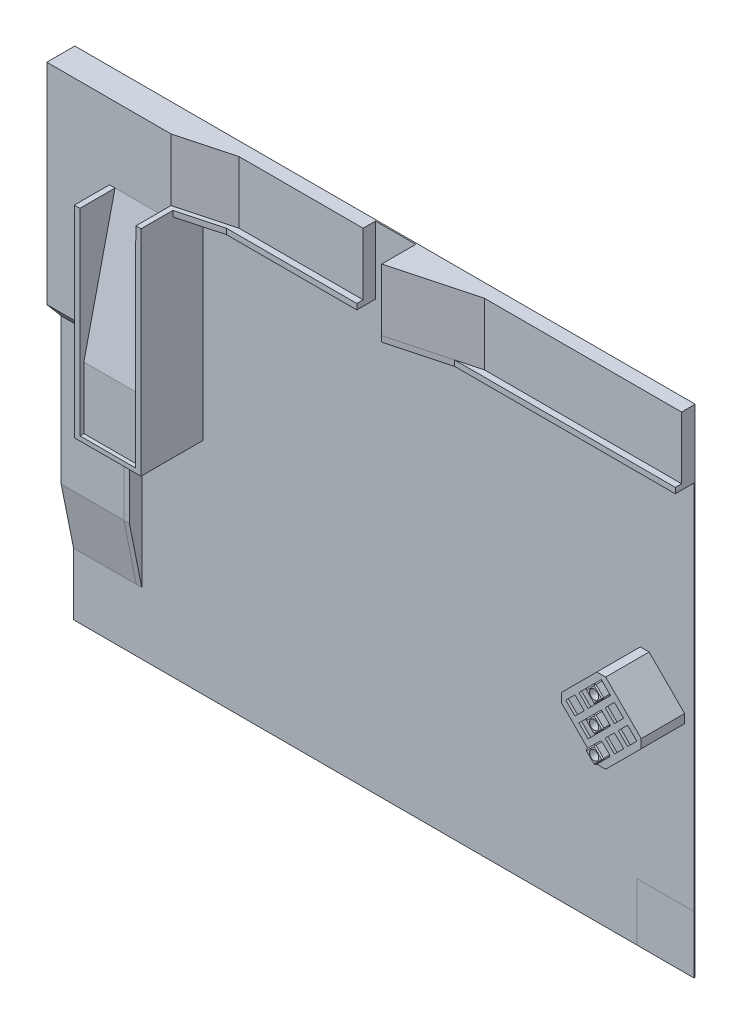
from build123d import *

# Parameters (mm, degrees)
SKETCH_1_W                  = 10000
SKETCH_1_H                  = 8000
EXTRUDE_1_DEPTH             = 20
SKETCH_2_W                  = 4483
SKETCH_2_H                  = 1000
EXTRUDE_2_DEPTH             = 200
EXTRUDE_3_DEPTH             = 1000
SKETCH_5_W                  = 2867
SKETCH_5_H                  = 1000
EXTRUDE_4_DEPTH             = 200
EXTRUDE_5_DEPTH             = 1000
SKETCH_7_W                  = 2000
SKETCH_7_H                  = 3383
EXTRUDE_6_DEPTH             = 431.88915
EXTRUDE_7_DEPTH             = 2000
SKETCH_10_W                 = 1100
SKETCH_10_H                 = 934.292466456
CUT_EXTRUDE_1_DEPTH         = 2176.14786
EXTRUDE_START               = -4e-06
SKETCH_11_W                 = 1100
SKETCH_11_H                 = 431.889147349
EXTRUDE_8_DEPTH             = 2176.14786
SKETCH_12_W                 = 900
SKETCH_12_H                 = 1000
EXTRUDE_9_DEPTH             = 934.292466
EXTRUDE_10_DEPTH            = 1100
SKETCH_16_W                 = 1100
SKETCH_16_H                 = 200
EXTRUDE_11_DEPTH            = 2622
EXTRUDE_12_DEPTH            = 1100
EXTRUDE_13_DEPTH            = 1018
SKETCH_22_W                 = 82.675943171
SKETCH_22_H                 = 996.089113944
EXTRUDE_14_DEPTH            = 206.852144
SKETCH_23_W                 = 1000
SKETCH_23_H                 = 90
EXTRUDE_15_DEPTH            = 2782.251832
CUT_EXTRUDE_2_DEPTH         = 308
SKETCH_25_W                 = 296.558009181
SKETCH_25_H                 = 236.726130136
CUT_EXTRUDE_3_DEPTH         = 3067
EXTRUDE_START_2             = -4483
SKETCH_26_W                 = 299.612595247
SKETCH_26_H                 = 90
EXTRUDE_16_DEPTH            = 4483
EXTRUDE_17_DEPTH            = 90
EXTRUDE_18_DEPTH            = 700
CHAMFER_1_SIZE              = 100
CUT_EXTRUDE_5_DEPTH         = 42
PATTERN_LINEAR_2_COUNT      = 3
PATTERN_LINEAR_2_PITCH      = 300
PATTERN_LINEAR_2_COUNT_DIR2 = 3
PATTERN_LINEAR_2_PITCH_DIR2 = 300
EXTRUDE_19_DEPTH            = 158
CHAMFER_4_SIZE              = 18
CHAMFER_5_SIZE              = 18
EXTRUDE_20_DEPTH            = 116
CHAMFER_6_SIZE              = 18
CHAMFER_7_SIZE              = 18
EXTRUDE_21_DEPTH            = 116
CHAMFER_8_SIZE              = 18
SKETCH_41_R                 = 75
CUT_EXTRUDE_6_DEPTH         = 164
SKETCH_42_R                 = 75
CUT_EXTRUDE_7_DEPTH         = 164
SKETCH_43_R                 = 75
CUT_EXTRUDE_8_DEPTH         = 164


with BuildPart() as part:
    # 草图1 → 凸台-拉伸1 (new body)
    with BuildSketch(Plane.XY):
        with Locations((5000, 4000)):
            Rectangle(SKETCH_1_W, SKETCH_1_H)
    extrude(amount=EXTRUDE_1_DEPTH)

    # 草图2 → 凸台-拉伸2 (add)
    with BuildSketch(Plane.XY.offset(20)):
        with Locations((7758.5, 7500)):
            Rectangle(SKETCH_2_W, SKETCH_2_H)
    extrude(amount=EXTRUDE_2_DEPTH)

    # 草图3 → 凸台-拉伸3 (add)
    with BuildSketch(Plane(origin=(0, 8000, 0), x_dir=(1, 0, 0), z_dir=(0, 1, 0))):
        Polygon((5517, -220), (5517, -570), (6823, -220), align=None)
    extrude(amount=-EXTRUDE_3_DEPTH)

    # 草图5 → 凸台-拉伸4 (add)
    with BuildSketch(Plane.XY.offset(20)):
        with Locations((3433.5, 7500)):
            Rectangle(SKETCH_5_W, SKETCH_5_H)
    extrude(amount=EXTRUDE_4_DEPTH)

    # 草图6 → 凸台-拉伸5 (add)
    with BuildSketch(Plane(origin=(0, 8000, 0), x_dir=(1, 0, 0), z_dir=(0, 1, 0))):
        Polygon((2000, -220), (2865.42207963, -220), (2000, -451.889147349), align=None)
    extrude(amount=-EXTRUDE_5_DEPTH)

    # 草图7 → 凸台-拉伸6 (add)
    with BuildSketch(Plane.XY.offset(20)):
        with Locations((1000, 6308.5)):
            Rectangle(SKETCH_7_W, SKETCH_7_H)
    extrude(amount=EXTRUDE_6_DEPTH)

    # 草图9 → 凸台-拉伸7 (add)
    with BuildSketch(Plane(origin=(2000, 0, 0), x_dir=(0, 0, -1), z_dir=(1, 0, 0))):
        Polygon((-451.889147349, 4617), (-451.889147349, 6793.147855873), (-954.292466456, 4617), align=None)
    extrude(amount=-EXTRUDE_7_DEPTH)

    # 草图10 → 切除-拉伸1 (cut)
    with BuildSketch(Plane.XZ.offset(-4617)):
        with Locations((550, 487.146233228)):
            Rectangle(SKETCH_10_W, SKETCH_10_H)
    extrude(amount=-CUT_EXTRUDE_1_DEPTH, mode=Mode.SUBTRACT)

    # 草图11 → 凸台-拉伸8 (add)
    with BuildSketch(Plane.XZ.offset(-6793.147855873).offset(EXTRUDE_START)):
        with Locations((550, 235.944573675)):
            Rectangle(SKETCH_11_W, SKETCH_11_H)
    extrude(amount=EXTRUDE_8_DEPTH)

    # 草图12 → 凸台-拉伸9 (add)
    with BuildSketch(Plane.XY.offset(20)):
        with Locations((1550, 4117)):
            Rectangle(SKETCH_12_W, SKETCH_12_H)
    extrude(amount=EXTRUDE_9_DEPTH)

    # 草图14 → 凸台-拉伸10 (add)
    with BuildSketch(Plane.ZY.offset(-1100)):
        Polygon((220, 4342), (220, 4617), (451.889147349, 4617), align=None)
    extrude(amount=EXTRUDE_10_DEPTH)

    # 草图16 → 凸台-拉伸11 (add)
    with BuildSketch(Plane.XZ.offset(-4617)):
        with Locations((550, 120)):
            Rectangle(SKETCH_16_W, SKETCH_16_H)
    extrude(amount=EXTRUDE_11_DEPTH)

    # 草图17 → 凸台-拉伸12 (add)
    with BuildSketch(Plane.ZY):
        Polygon((20, 1995), (20, 1000), (220, 1995), align=None)
    extrude(amount=-EXTRUDE_12_DEPTH)

    # 草图18 → 凸台-拉伸13 (add)
    with BuildSketch(Plane.XY):
        Polygon((1100, 6793.147855873), (1010, 6793.147855873), (1010, 3545.906358022), (2084.748167595, 3545.906358022), (2084.748167595, 6793.147855873), (2000, 6793.147855873), (2000, 3617), (1100, 3617), align=None)
    extrude(amount=EXTRUDE_13_DEPTH)

    # 草图22 → 凸台-拉伸14 (add)
    with BuildSketch(Plane(origin=(0, 6793.147855873, 0), x_dir=(1, 0, 0), z_dir=(0, 1, 0))):
        with Locations((2043.41019601, -519.955443028)):
            Rectangle(SKETCH_22_W, SKETCH_22_H)
    extrude(amount=EXTRUDE_14_DEPTH)

    # 草图23 → 凸台-拉伸15 (add)
    with BuildSketch(Plane(origin=(2084.748167595, 0, 0), x_dir=(0, 0, -1), z_dir=(1, 0, 0))):
        with Locations((-521.910886056, 6955)):
            Rectangle(SKETCH_23_W, SKETCH_23_H)
    extrude(amount=EXTRUDE_15_DEPTH)

    # 草图24 → 切除-拉伸2 (cut)
    with BuildSketch(Plane(origin=(0, 7000, 0), x_dir=(1, 0, 0), z_dir=(0, 1, 0))):
        Polygon((2084.748167595, -1018), (2084.748167595, -504.330547982), (2764.317775175, -321.523481303), (4867, -321.523481303), (4867, -1021.910886056), align=None)
    extrude(amount=-CUT_EXTRUDE_2_DEPTH, mode=Mode.SUBTRACT)


with BuildPart() as cut_extrude_2_piece_1:
    # of the separate pieces the step leaves, piece 1, a body of its own (cut_extrude_2_pieces)
    add(part.part.solids().sort_by_distance((0, 0, 0))[0])

    # 草图26 → 凸台-拉伸16 (add)
    with BuildSketch(Plane(origin=(10000, 0, 0), x_dir=(0, 0, -1), z_dir=(1, 0, 0)).offset(EXTRUDE_START_2)):
        with Locations((-171.71718368, 6955)):
            Rectangle(SKETCH_26_W, SKETCH_26_H)
    extrude(amount=EXTRUDE_16_DEPTH)

    # 草图27 → 凸台-拉伸17 (add)
    with BuildSketch(Plane.XZ.offset(-7000)):
        Polygon((5517, 570), (5517, 321.523481303), (6444.172381196, 321.523481303), align=None)
    extrude(amount=EXTRUDE_17_DEPTH)

    # 草图32 → 凸台-拉伸18 (add)
    with BuildSketch(Plane.XY.offset(20)):
        Polygon((9920.278281584, 3545.906358022), (9206.100432586, 4260.084207021), (8491.922583587, 3545.906358022), (9206.100432586, 2831.728509024), align=None)
    extrude(amount=EXTRUDE_18_DEPTH)

    # 倒角1
    chamfer_1_edges = [cut_extrude_2_piece_1.edges().sort_by_distance(p)[0] for p in [
        (9206.100432586, 2831.728509024, 370),
        (9920.278281584, 3545.906358022, 370),
        (9206.100432586, 4260.084207021, 370),
        (8491.922583587, 3545.906358022, 370),
    ]]
    chamfer(chamfer_1_edges, length=CHAMFER_1_SIZE)

    # 草图35 → 切除-拉伸5 (cut)
    with BuildSketch(Plane.XY.offset(720)):
        Polygon((8633.343939825, 3545.906358022), (8781.836363874, 3694.398782071), (8930.328787923, 3545.906358022), (8781.836363874, 3397.413933973), align=None)
    cut_extrude_5 = extrude(amount=-CUT_EXTRUDE_5_DEPTH, mode=Mode.SUBTRACT)

    # 阵列(线性)2: Cut-Extrude 5 3 × 3
    with Locations(*[Vector(0.7071067811865527, -0.7071067811865424, 0) * (i * PATTERN_LINEAR_2_PITCH) + Vector(0.7071067811865408, 0.7071067811865542, 0) * (j * PATTERN_LINEAR_2_PITCH_DIR2) for i in range(PATTERN_LINEAR_2_COUNT) for j in range(PATTERN_LINEAR_2_COUNT_DIR2) if (i, j) != (0, 0)]):
        add(cut_extrude_5, mode=Mode.SUBTRACT)

    # 草图36 → 凸台-拉伸19 (add)
    with BuildSketch(Plane.XY.offset(678)):
        Polygon((9057.608008537, 3121.64228931), (9206.100432586, 3270.134713359), (9354.592856635, 3121.64228931), (9206.100432586, 2973.149865261), align=None)
    extrude(amount=EXTRUDE_19_DEPTH)

    # 倒角4
    chamfer_4_edges = [cut_extrude_2_piece_1.edges().sort_by_distance(p)[0] for p in [
        (9131.854220561, 3047.396077286, 836),
        (9280.34664461, 3047.396077286, 836),
        (9280.34664461, 3195.888501335, 836),
        (9131.854220561, 3195.888501335, 836),
    ]]
    chamfer(chamfer_4_edges, length=CHAMFER_4_SIZE)

    # 倒角5
    chamfer_5_edges = [cut_extrude_2_piece_1.edges().sort_by_distance(p)[0] for p in [
        (9057.608008537, 3121.64228931, 769),
        (9206.100432586, 3270.134713359, 769),
        (9354.592856635, 3121.64228931, 769),
        (9206.100432586, 2973.149865261, 769),
    ]]
    chamfer(chamfer_5_edges, length=CHAMFER_5_SIZE)


with BuildPart() as cut_extrude_2_piece_2:
    # of the separate pieces the step leaves, piece 2, a body of its own (cut_extrude_2_pieces)
    add(part.part.solids().sort_by_distance((2084.748167595, 6910, 1021.910886056))[0])

    # 草图25 → 切除-拉伸3 (cut)
    with BuildSketch(Plane(origin=(2084.748167595, 0, 0), x_dir=(0, 0, -1), z_dir=(1, 0, 0))):
        with Locations((-1038.303536701, 6926.915216344)):
            Rectangle(SKETCH_25_W, SKETCH_25_H)
    extrude(amount=CUT_EXTRUDE_3_DEPTH, mode=Mode.SUBTRACT)


with BuildPart() as body_2:
    # 草图37 → 凸台-拉伸20 (new body)
    with BuildSketch(Plane.XY.offset(720)):
        Polygon((9057.608008537, 3545.906358022), (9206.100432586, 3397.413933973), (9354.592856635, 3545.906358022), (9206.100432586, 3694.398782071), align=None)
    extrude(amount=EXTRUDE_20_DEPTH)

    # 倒角6
    chamfer_6_edges = [body_2.edges().sort_by_distance(p)[0] for p in [
        (9280.34664461, 3471.660145998, 836),
        (9280.34664461, 3620.152570047, 836),
        (9131.854220561, 3620.152570047, 836),
        (9131.854220561, 3471.660145998, 836),
    ]]
    chamfer(chamfer_6_edges, length=CHAMFER_6_SIZE)

    # 倒角7
    chamfer_7_edges = [body_2.edges().sort_by_distance(p)[0] for p in [
        (9206.100432586, 3694.398782071, 769),
        (9354.592856635, 3545.906358022, 769),
        (9057.608008537, 3545.906358022, 769),
        (9206.100432586, 3397.413933973, 769),
    ]]
    chamfer(chamfer_7_edges, length=CHAMFER_7_SIZE)


with BuildPart() as body_3:
    # 草图38 → 凸台-拉伸21 (new body)
    with BuildSketch(Plane.XY.offset(720)):
        Polygon((9057.608008537, 3970.170426734), (9206.100432586, 4118.662850783), (9354.592856635, 3970.170426734), (9206.100432586, 3821.678002685), align=None)
    extrude(amount=EXTRUDE_21_DEPTH)

    # 倒角8
    chamfer_8_edges = [body_3.edges().sort_by_distance(p)[0] for p in [
        (9280.34664461, 4044.416638759, 836),
        (9131.854220561, 4044.416638759, 836),
        (9131.854220561, 3895.92421471, 836),
        (9280.34664461, 3895.92421471, 836),
        (9057.608008537, 3970.170426734, 778),
        (9206.100432586, 4118.662850783, 778),
        (9354.592856635, 3970.170426734, 778),
        (9206.100432586, 3821.678002685, 778),
    ]]
    chamfer(chamfer_8_edges, length=CHAMFER_8_SIZE)


with BuildPart() as cut_extrude_6_tool:
    # 草图41 → 切除-拉伸6 (new body)
    with BuildSketch(Plane.XY.offset(836)):
        with Locations((9206.100432586, 3970.170426734)):
            Circle(SKETCH_41_R)
    extrude(amount=-CUT_EXTRUDE_6_DEPTH)


with BuildPart() as cut_extrude_2_piece_1_1:
    add(cut_extrude_2_piece_1.part)

    # 切除-拉伸6: cut by cut_extrude_6_tool
    add(cut_extrude_6_tool.part, mode=Mode.SUBTRACT)


with BuildPart() as body_3_1:
    add(body_3.part)

    # 切除-拉伸6: cut by cut_extrude_6_tool
    add(cut_extrude_6_tool.part, mode=Mode.SUBTRACT)


with BuildPart() as cut_extrude_7_tool:
    # 草图42 → 切除-拉伸7 (new body)
    with BuildSketch(Plane.XY.offset(836)):
        with Locations((9206.100432586, 3545.906358022)):
            Circle(SKETCH_42_R)
    extrude(amount=-CUT_EXTRUDE_7_DEPTH)


with BuildPart() as cut_extrude_2_piece_1_2:
    add(cut_extrude_2_piece_1_1.part)

    # 切除-拉伸7: cut by cut_extrude_7_tool
    add(cut_extrude_7_tool.part, mode=Mode.SUBTRACT)

    # 草图43 → 切除-拉伸8 (cut)
    with BuildSketch(Plane.XY.offset(836)):
        with Locations((9206.100432586, 3121.64228931)):
            Circle(SKETCH_43_R)
    extrude(amount=-CUT_EXTRUDE_8_DEPTH, mode=Mode.SUBTRACT)


with BuildPart() as body_2_1:
    add(body_2.part)

    # 切除-拉伸7: cut by cut_extrude_7_tool
    add(cut_extrude_7_tool.part, mode=Mode.SUBTRACT)


solid = Compound([body_3_1.part, cut_extrude_2_piece_1_2.part, body_2_1.part])
